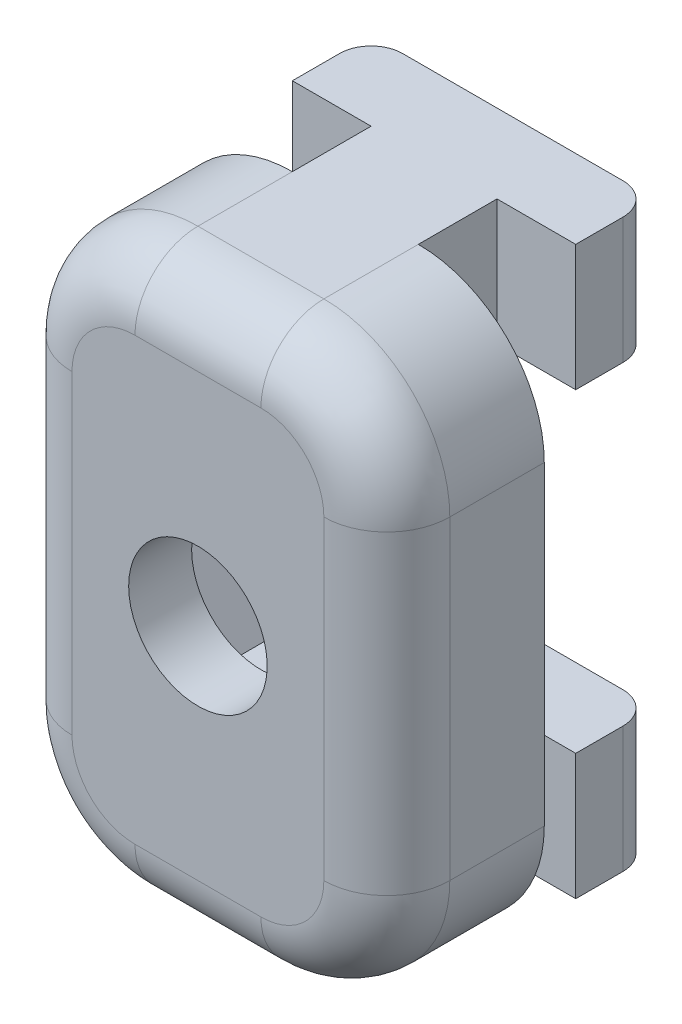
from build123d import *

# Parameters (mm, degrees)
BOSS_EXTRU_3_DEPTH      = 4
ESQUISSE3_W             = 12
ESQUISSE3_H             = 5
BOSS_EXTRU_4_DEPTH      = 5
ENL_V_MAT_EXTRU_1_REACH = 7
ESQUISSE4_R             = 2.2
ENL_V_MAT_EXTRU_2_DEPTH = 3
CONG_1_R                = 4
CONG_2_R                = 2


with BuildPart() as part:
    # Esquisse2 → Boss.-Extru.3 (new body)
    with BuildSketch(Plane(origin=(0, 0, 0), x_dir=(1, 0, 0), z_dir=(0, 1, 0))):
        with BuildLine():
            Line((11.568725398, 38.128215269), (18.568725398, 38.128215269))
            ThreePointArc((18.568725398, 38.128215269), (19.275832179, 37.83532205), (19.568725398, 37.128215269))
            Line((19.568725398, 37.128215269), (19.568725398, 35.628215269))
            Line((19.568725398, 35.628215269), (17.068725398, 35.628215269))
            Line((17.068725398, 35.628215269), (17.068725398, 33.128215269))
            Line((17.068725398, 33.128215269), (21.068725398, 33.128215269))
            Line((21.068725398, 33.128215269), (21.068725398, 28.128215269))
            Line((21.068725398, 28.128215269), (9.068725398, 28.128215269))
            Line((9.068725398, 28.128215269), (9.068725398, 33.128215269))
            Line((9.068725398, 33.128215269), (13.068725398, 33.128215269))
            Line((13.068725398, 33.128215269), (13.068725398, 35.628215269))
            Line((13.068725398, 35.628215269), (10.568725398, 35.628215269))
            Line((10.568725398, 35.628215269), (10.568725398, 37.128215269))
            ThreePointArc((10.568725398, 37.128215269), (10.861618616, 37.83532205), (11.568725398, 38.128215269))
        make_face()
    extrude(amount=BOSS_EXTRU_3_DEPTH)

    # Esquisse3 → Boss.-Extru.4 (add)
    with BuildSketch(Plane(origin=(0, 4, 0), x_dir=(1, 0, 0), z_dir=(0, 1, 0))):
        with Locations((15.068725398, 30.628215269)):
            Rectangle(ESQUISSE3_W, ESQUISSE3_H)
    extrude(amount=BOSS_EXTRU_4_DEPTH)

    # Symétrie1: part across plane


with BuildPart() as part_1:
    add(part.part)
    add(part.part.mirror(Plane.ZX.offset(9)))

    # Esquisse4 → Enlèv. mat.-Extru.1 (cut, up to next)
    with BuildSketch(Plane(origin=(0, 0, -33.128215269), x_dir=(-1, 0, 0), z_dir=(0, 0, -1)), mode=Mode.PRIVATE) as enl_v_mat_extru_1_sk1:
        with Locations((-15.068725398, 9)):
            Circle(ESQUISSE4_R)
    enl_v_mat_extru_1_tool1 = extrude(enl_v_mat_extru_1_sk1.sketch, amount=-ENL_V_MAT_EXTRU_1_REACH, mode=Mode.PRIVATE) & part_1.part
    add(enl_v_mat_extru_1_tool1.solids().sort_by_distance((15.068725, 9, -33.128215))[0], mode=Mode.SUBTRACT)

    # Esquisse5 → Enlèv. mat.-Extru.2 (cut)
    with BuildSketch(Plane(origin=(0, 0, -33.128215269), x_dir=(-1, 0, 0), z_dir=(0, 0, -1))):
        Polygon((-13.047999455, 12.5), (-17.08945134, 12.5), (-19.110177282, 9), (-17.08945134, 5.5), (-13.047999455, 5.5), (-11.027273513, 9), align=None)
    extrude(amount=-ENL_V_MAT_EXTRU_2_DEPTH, mode=Mode.SUBTRACT)

    # Congé1
    cong_1_edges = [part_1.edges().sort_by_distance(p)[0] for p in [
        (9.068725398, 0, -30.628215269),
        (9.068725398, 18, -30.628215269),
        (21.068725398, 18, -30.628215269),
        (21.068725398, 0, -30.628215269),
    ]]
    fillet(cong_1_edges, radius=CONG_1_R)

    # Congé2
    cong_2_edges = [part_1.edges().sort_by_distance(p)[0] for p in [
        (9.068725398, 9, -28.128215269),
        (15.068725398, 0, -28.128215269),
        (21.068725398, 9, -28.128215269),
        (15.068725398, 18, -28.128215269),
        (19.897152522, 16.828427125, -28.128215269),
        (19.897152522, 1.171572875, -28.128215269),
        (10.240298273, 16.828427125, -28.128215269),
        (10.240298273, 1.171572875, -28.128215269),
    ]]
    fillet(cong_2_edges, radius=CONG_2_R)


solid = part_1.part
